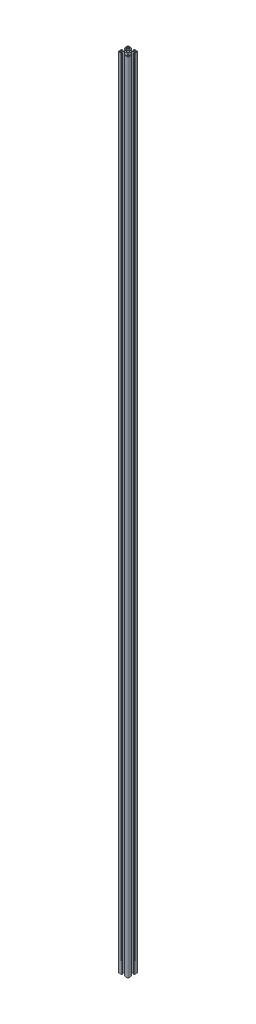
from build123d import *

# Parameters (mm, degrees)
SKETCH_3_R      = 3.4
EXTRUDE_1_DEPTH = 2400


with BuildPart() as part:
    # 草图3 → 凸台-拉伸1 (new body)
    with BuildSketch(Plane(origin=(0, 0, 0), x_dir=(1, 0, 0), z_dir=(0, 1, 0))):
        with BuildLine():
            Line((-15, -12.5), (-15, -5.4))
            ThreePointArc((-15, -5.4), (-14.941421356, -5.258578644), (-14.8, -5.2))
            Line((-14.8, -5.2), (-14.4, -5.2))
            ThreePointArc((-14.4, -5.2), (-14.258578644, -5.141421356), (-14.2, -5))
            Line((-14.2, -5), (-14.2, -4.3))
            ThreePointArc((-14.2, -4.3), (-14.141421356, -4.158578644), (-14, -4.1))
            Line((-14, -4.1), (-13.2, -4.1))
            Line((-13.2, -4.1), (-13.2, -8.25))
            Line((-13.2, -8.25), (-9.522792206, -8.25))
            Line((-9.522792206, -8.25), (-5.8, -4.527207794))
            Line((-5.8, -4.527207794), (-5.8, 4.527207794))
            Line((-5.8, 4.527207794), (-9.522792206, 8.25))
            Line((-9.522792206, 8.25), (-13.2, 8.25))
            Line((-13.2, 8.25), (-13.2, 4.1))
            Line((-13.2, 4.1), (-14, 4.1))
            ThreePointArc((-14, 4.1), (-14.141421356, 4.158578644), (-14.2, 4.3))
            Line((-14.2, 4.3), (-14.2, 5))
            ThreePointArc((-14.2, 5), (-14.258578644, 5.141421356), (-14.4, 5.2))
            Line((-14.4, 5.2), (-14.8, 5.2))
            ThreePointArc((-14.8, 5.2), (-14.941421356, 5.258578644), (-15, 5.4))
            Line((-15, 5.4), (-15, 12.5))
            ThreePointArc((-15, 12.5), (-14.267766953, 14.267766953), (-12.5, 15))
            Line((-12.5, 15), (-5.4, 15))
            ThreePointArc((-5.4, 15), (-5.258578644, 14.941421356), (-5.2, 14.8))
            Line((-5.2, 14.8), (-5.2, 14.4))
            ThreePointArc((-5.2, 14.4), (-5.141421356, 14.258578644), (-5, 14.2))
            Line((-5, 14.2), (-4.3, 14.2))
            ThreePointArc((-4.3, 14.2), (-4.158578644, 14.141421356), (-4.1, 14))
            Line((-4.1, 14), (-4.1, 13.2))
            Line((-4.1, 13.2), (-8.25, 13.2))
            Line((-8.25, 13.2), (-8.25, 9.522792206))
            Line((-8.25, 9.522792206), (-4.527207794, 5.8))
            Line((-4.527207794, 5.8), (4.527207794, 5.8))
            Line((4.527207794, 5.8), (8.25, 9.522792206))
            Line((8.25, 9.522792206), (8.25, 13.2))
            Line((8.25, 13.2), (4.1, 13.2))
            Line((4.1, 13.2), (4.1, 14))
            ThreePointArc((4.1, 14), (4.158578644, 14.141421356), (4.3, 14.2))
            Line((4.3, 14.2), (5, 14.2))
            ThreePointArc((5, 14.2), (5.141421356, 14.258578644), (5.2, 14.4))
            Line((5.2, 14.4), (5.2, 14.8))
            ThreePointArc((5.2, 14.8), (5.258578644, 14.941421356), (5.4, 15))
            Line((5.4, 15), (12.5, 15))
            ThreePointArc((12.5, 15), (14.267766953, 14.267766953), (15, 12.5))
            Line((15, 12.5), (15, 5.4))
            ThreePointArc((15, 5.4), (14.941421356, 5.258578644), (14.8, 5.2))
            Line((14.8, 5.2), (14.4, 5.2))
            ThreePointArc((14.4, 5.2), (14.258578644, 5.141421356), (14.2, 5))
            Line((14.2, 5), (14.2, 4.3))
            ThreePointArc((14.2, 4.3), (14.141421356, 4.158578644), (14, 4.1))
            Line((14, 4.1), (13.2, 4.1))
            Line((13.2, 4.1), (13.2, 8.25))
            Line((13.2, 8.25), (9.522792206, 8.25))
            Line((9.522792206, 8.25), (5.8, 4.527207794))
            Line((5.8, 4.527207794), (5.8, -4.527207794))
            Line((5.8, -4.527207794), (9.522792206, -8.25))
            Line((9.522792206, -8.25), (13.2, -8.25))
            Line((13.2, -8.25), (13.2, -4.1))
            Line((13.2, -4.1), (14, -4.1))
            ThreePointArc((14, -4.1), (14.141421356, -4.158578644), (14.2, -4.3))
            Line((14.2, -4.3), (14.2, -5))
            ThreePointArc((14.2, -5), (14.258578644, -5.141421356), (14.4, -5.2))
            Line((14.4, -5.2), (14.8, -5.2))
            ThreePointArc((14.8, -5.2), (14.941421356, -5.258578644), (15, -5.4))
            Line((15, -5.4), (15, -12.5))
            ThreePointArc((15, -12.5), (14.267766953, -14.267766953), (12.5, -15))
            Line((12.5, -15), (5.4, -15))
            ThreePointArc((5.4, -15), (5.258578644, -14.941421356), (5.2, -14.8))
            Line((5.2, -14.8), (5.2, -14.4))
            ThreePointArc((5.2, -14.4), (5.141421356, -14.258578644), (5, -14.2))
            Line((5, -14.2), (4.3, -14.2))
            ThreePointArc((4.3, -14.2), (4.158578644, -14.141421356), (4.1, -14))
            Line((4.1, -14), (4.1, -13.2))
            Line((4.1, -13.2), (8.25, -13.2))
            Line((8.25, -13.2), (8.25, -9.522792206))
            Line((8.25, -9.522792206), (4.527207794, -5.8))
            Line((4.527207794, -5.8), (-4.527207794, -5.8))
            Line((-4.527207794, -5.8), (-8.25, -9.522792206))
            Line((-8.25, -9.522792206), (-8.25, -13.2))
            Line((-8.25, -13.2), (-4.1, -13.2))
            Line((-4.1, -13.2), (-4.1, -14))
            ThreePointArc((-4.1, -14), (-4.158578644, -14.141421356), (-4.3, -14.2))
            Line((-4.3, -14.2), (-5, -14.2))
            ThreePointArc((-5, -14.2), (-5.141421356, -14.258578644), (-5.2, -14.4))
            Line((-5.2, -14.4), (-5.2, -14.8))
            ThreePointArc((-5.2, -14.8), (-5.258578644, -14.941421356), (-5.4, -15))
            Line((-5.4, -15), (-12.5, -15))
            ThreePointArc((-12.5, -15), (-14.267766953, -14.267766953), (-15, -12.5))
        make_face()
        Circle(SKETCH_3_R, mode=Mode.SUBTRACT)
        with BuildLine():
            Line((-13.2, -12.2), (-13.2, -11.05))
            ThreePointArc((-13.2, -11.05), (-12.907106781, -10.342893219), (-12.2, -10.05))
            Line((-12.2, -10.05), (-11.05, -10.05))
            ThreePointArc((-11.05, -10.05), (-10.342893219, -10.342893219), (-10.05, -11.05))
            Line((-10.05, -11.05), (-10.05, -12.2))
            ThreePointArc((-10.05, -12.2), (-10.342893219, -12.907106781), (-11.05, -13.2))
            Line((-11.05, -13.2), (-12.2, -13.2))
            ThreePointArc((-12.2, -13.2), (-12.907106781, -12.907106781), (-13.2, -12.2))
        make_face(mode=Mode.SUBTRACT)
        with BuildLine():
            Line((-10.05, 12.2), (-10.05, 11.05))
            ThreePointArc((-10.05, 11.05), (-10.342893219, 10.342893219), (-11.05, 10.05))
            Line((-11.05, 10.05), (-12.2, 10.05))
            ThreePointArc((-12.2, 10.05), (-12.907106781, 10.342893219), (-13.2, 11.05))
            Line((-13.2, 11.05), (-13.2, 12.2))
            ThreePointArc((-13.2, 12.2), (-12.907106781, 12.907106781), (-12.2, 13.2))
            Line((-12.2, 13.2), (-11.05, 13.2))
            ThreePointArc((-11.05, 13.2), (-10.342893219, 12.907106781), (-10.05, 12.2))
        make_face(mode=Mode.SUBTRACT)
        with BuildLine():
            Line((13.2, 12.2), (13.2, 11.05))
            ThreePointArc((13.2, 11.05), (12.907106781, 10.342893219), (12.2, 10.05))
            Line((12.2, 10.05), (11.05, 10.05))
            ThreePointArc((11.05, 10.05), (10.342893219, 10.342893219), (10.05, 11.05))
            Line((10.05, 11.05), (10.05, 12.2))
            ThreePointArc((10.05, 12.2), (10.342893219, 12.907106781), (11.05, 13.2))
            Line((11.05, 13.2), (12.2, 13.2))
            ThreePointArc((12.2, 13.2), (12.907106781, 12.907106781), (13.2, 12.2))
        make_face(mode=Mode.SUBTRACT)
        with BuildLine():
            Line((10.05, -12.2), (10.05, -11.05))
            ThreePointArc((10.05, -11.05), (10.342893219, -10.342893219), (11.05, -10.05))
            Line((11.05, -10.05), (12.2, -10.05))
            ThreePointArc((12.2, -10.05), (12.907106781, -10.342893219), (13.2, -11.05))
            Line((13.2, -11.05), (13.2, -12.2))
            ThreePointArc((13.2, -12.2), (12.907106781, -12.907106781), (12.2, -13.2))
            Line((12.2, -13.2), (11.05, -13.2))
            ThreePointArc((11.05, -13.2), (10.342893219, -12.907106781), (10.05, -12.2))
        make_face(mode=Mode.SUBTRACT)
    extrude(amount=EXTRUDE_1_DEPTH)


solid = part.part
